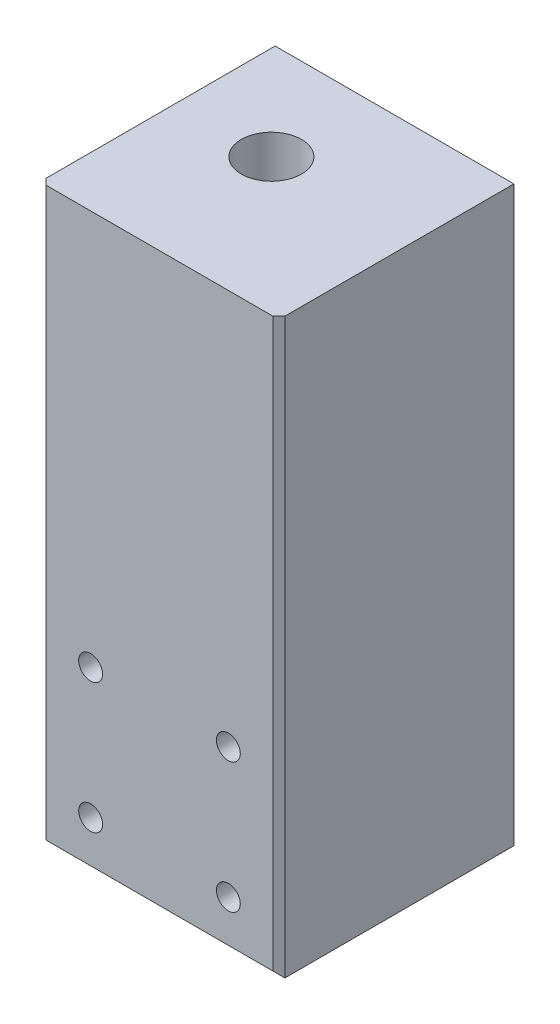
from build123d import *

# Parameters (mm, degrees)
PRIMARY_START           = -87.9
SKETCH2_W               = 20.25
SKETCH2_H               = 60
SKETCH2_W_2             = 43.25
PRIMARY_EXTRUSION_DEPTH = 62.5
SKETCH3_R               = 3.175
CUT_EXTRUDE2_DEPTH      = 25.4
CUT_EXTRUDE3_START      = -62.5
SKETCH3_2_R             = 3.175
CUT_EXTRUDE3_DEPTH      = 6.35
CHAMFER1_SIZE           = 1.5875
CUT_EXTRUDE4_DEPTH      = 6.35
CUT_EXTRUDE5_DEPTH      = 153.4


with BuildPart() as part:
    # Sketch2 → Primary Extrusion (new body)
    with BuildSketch(Plane.XY.offset(PRIMARY_START)):
        with Locations((-135.5, 30)):
            Rectangle(SKETCH2_W, SKETCH2_H)
        with BuildLine():
            ThreePointArc((-132.325, 7), (-135.625, 3.7), (-138.925, 7))
            ThreePointArc((-138.925, 7), (-135.625, 10.3), (-132.325, 7))
        make_face(mode=Mode.SUBTRACT)
        with BuildLine():
            ThreePointArc((-132.325, 53), (-135.625, 49.7), (-138.925, 53))
            ThreePointArc((-138.925, 53), (-135.625, 56.3), (-132.325, 53))
        make_face(mode=Mode.SUBTRACT)
        with BuildLine():
            ThreePointArc((-138.925, 7), (-135.625, 3.7), (-132.325, 7))
            ThreePointArc((-132.325, 7), (-135.625, 10.3), (-138.925, 7))
        make_face()
        with BuildLine():
            ThreePointArc((-138.925, 53), (-135.625, 49.7), (-132.325, 53))
            ThreePointArc((-132.325, 53), (-135.625, 56.3), (-138.925, 53))
        make_face()
        with Locations((-167.25, 30)):
            Rectangle(SKETCH2_W_2, SKETCH2_H)
        Polygon((-145.625, 60), (-125.375, 60), (-125.375, 152.4), (-188.875, 152.4), (-188.875, 60), align=None)
    extrude(amount=PRIMARY_EXTRUSION_DEPTH)

    # Sketch3 → Cut-Extrude2 (cut)
    with BuildSketch(Plane.XY.offset(-25.4)):
        with Locations((-138.815833333, 47.3)):
            Circle(SKETCH3_R)
        with Locations((-138.815833333, 12.7)):
            Circle(SKETCH3_R)
        with Locations((93.595, 47.3)):
            Circle(SKETCH3_R)
        with Locations((131.655, 47.3)):
            Circle(SKETCH3_R)
        with Locations((131.655, 12.7)):
            Circle(SKETCH3_R)
        with Locations((93.595, 12.7)):
            Circle(SKETCH3_R)
        with Locations((-175.434166667, 47.3)):
            Circle(SKETCH3_R)
        with Locations((-175.434166667, 12.7)):
            Circle(SKETCH3_R)
    extrude(amount=-CUT_EXTRUDE2_DEPTH, mode=Mode.SUBTRACT)

    # Sketch3_2 → Cut-Extrude3 (cut)
    with BuildSketch(Plane.XY.offset(-25.4).offset(CUT_EXTRUDE3_START)):
        with Locations((-138.815833333, 47.3)):
            Circle(SKETCH3_2_R)
        with Locations((-138.815833333, 12.7)):
            Circle(SKETCH3_2_R)
    extrude(amount=CUT_EXTRUDE3_DEPTH, mode=Mode.SUBTRACT)

    # Chamfer1
    chamfer1_edges = [part.edges().sort_by_distance(p)[0] for p in [
        (-157.125, 0, -25.4),
        (-125.375, 76.2, -25.4),
        (-188.875, 76.2, -25.4),
    ]]
    chamfer(chamfer1_edges, length=CHAMFER1_SIZE)

    # Sketch4 → Cut-Extrude4 (cut)
    with BuildSketch(Plane.XZ):
        with BuildLine():
            ThreePointArc((-153.189971157, -75.335028843), (-150.439971157, -78.085028843), (-147.689971157, -75.335028843))
            ThreePointArc((-147.689971157, -75.335028843), (-150.439971157, -72.585028843), (-153.189971157, -75.335028843))
        make_face()
        with BuildLine():
            ThreePointArc((-166.625, -80.9), (-163.875, -83.65), (-161.125, -80.9))
            ThreePointArc((-161.125, -80.9), (-163.875, -78.15), (-166.625, -80.9))
        make_face()
        with BuildLine():
            ThreePointArc((-180.060028843, -75.335028843), (-177.310028843, -78.085028843), (-174.560028843, -75.335028843))
            ThreePointArc((-174.560028843, -75.335028843), (-177.310028843, -72.585028843), (-180.060028843, -75.335028843))
        make_face()
        with BuildLine():
            ThreePointArc((-153.189971157, -48.464971157), (-150.439971157, -51.214971157), (-147.689971157, -48.464971157))
            ThreePointArc((-147.689971157, -48.464971157), (-150.439971157, -45.714971157), (-153.189971157, -48.464971157))
        make_face()
        with BuildLine():
            ThreePointArc((-166.625, -42.9), (-163.875, -45.65), (-161.125, -42.9))
            ThreePointArc((-161.125, -42.9), (-163.875, -40.15), (-166.625, -42.9))
        make_face()
        with BuildLine():
            ThreePointArc((-180.060028843, -48.464971157), (-177.310028843, -51.214971157), (-174.560028843, -48.464971157))
            ThreePointArc((-174.560028843, -48.464971157), (-177.310028843, -45.714971157), (-180.060028843, -48.464971157))
        make_face()
    extrude(amount=-CUT_EXTRUDE4_DEPTH, mode=Mode.SUBTRACT)

    # Sketch4_4 → Cut-Extrude5 (cut, through all)
    with BuildSketch(Plane.XZ):
        with BuildLine():
            ThreePointArc((-171.875, -61.9), (-163.875, -69.9), (-155.875, -61.9))
            ThreePointArc((-155.875, -61.9), (-163.875, -53.9), (-171.875, -61.9))
        make_face()
    extrude(amount=-CUT_EXTRUDE5_DEPTH, mode=Mode.SUBTRACT)


solid = part.part
